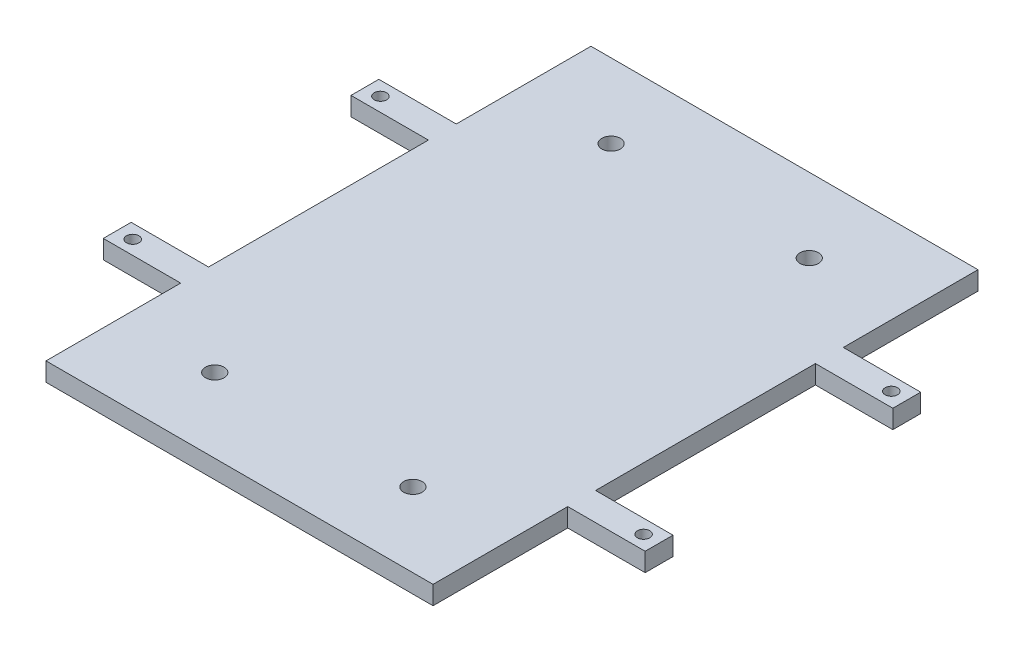
from build123d import *

# Parameters (mm, degrees)
BOSS_EXTRUDE1_DEPTH = 3
SKETCH2_R           = 1
CUT_EXTRUDE1_DEPTH  = 6
SKETCH3_R           = 1.5
CUT_EXTRUDE2_DEPTH  = 10


with BuildPart() as part:
    # Sketch1 → Boss-Extrude1 (new body)
    with BuildSketch(Plane(origin=(0, 0, 0), x_dir=(1, 0, 0), z_dir=(0, 1, 0))):
        Polygon((-43.75, 22.25), (-31.25, 22.25), (-31.25, 44), (31.25, 44), (31.25, 22.25), (43.75, 22.25), (43.75, 17.75), (31.25, 17.75), (31.25, -17.75), (43.75, -17.75), (43.75, -22.25), (31.25, -22.25), (31.25, -44), (-31.25, -44), (-31.25, -22.25), (-43.75, -22.25), (-43.75, -17.75), (-31.25, -17.75), (-31.25, 17.75), (-43.75, 17.75), align=None)
    extrude(amount=BOSS_EXTRUDE1_DEPTH)

    # Sketch2 → Cut-Extrude1 (cut)
    with BuildSketch(Plane.XZ):
        with Locations((-41.25, 20)):
            Circle(SKETCH2_R)
        with Locations((-41.25, -20)):
            Circle(SKETCH2_R)
        with Locations((41.25, -20)):
            Circle(SKETCH2_R)
        with Locations((41.25, 20)):
            Circle(SKETCH2_R)
    extrude(amount=-CUT_EXTRUDE1_DEPTH, mode=Mode.SUBTRACT)

    # Sketch3 → Cut-Extrude2 (cut)
    with BuildSketch(Plane(origin=(0, 3, 0), x_dir=(1, 0, 0), z_dir=(0, 1, 0))):
        with Locations((-16, 32)):
            Circle(SKETCH3_R)
        with Locations((16, 32)):
            Circle(SKETCH3_R)
        with Locations((16, -32)):
            Circle(SKETCH3_R)
        with Locations((-16, -32)):
            Circle(SKETCH3_R)
    extrude(amount=-CUT_EXTRUDE2_DEPTH, mode=Mode.SUBTRACT)


solid = part.part
